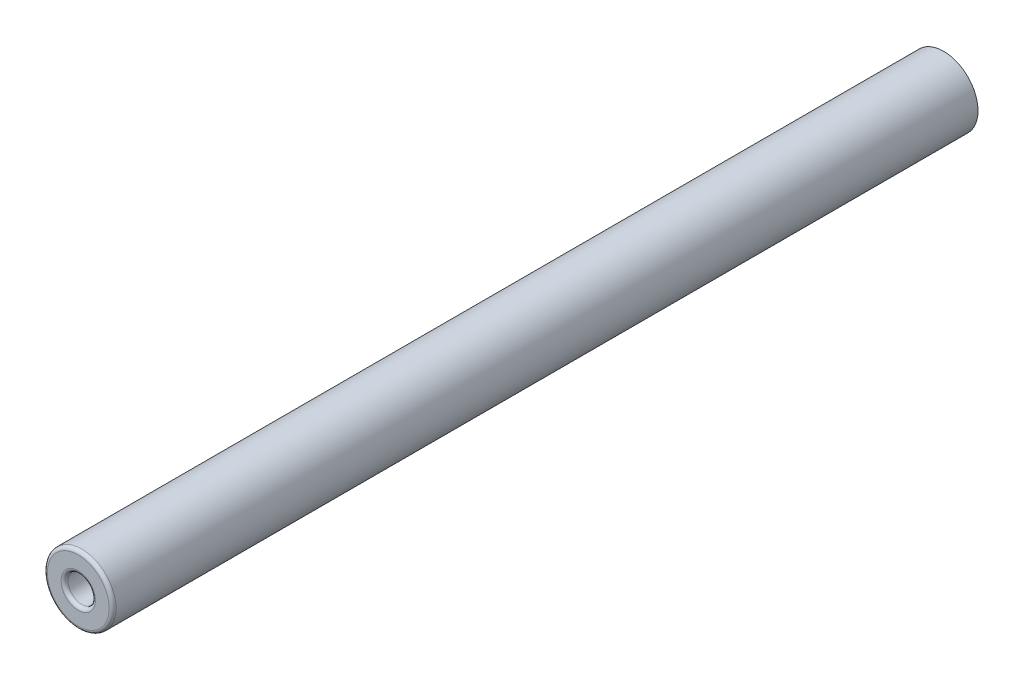
from build123d import *

# Parameters (mm, degrees)
SKETCH1_R           = 2.5
BOSS_EXTRUDE1_DEPTH = 63
SKETCH2_R           = 1
CUT_EXTRUDE1_DEPTH  = 10
FILLET1_R           = 0.25


with BuildPart() as part:
    # Sketch1 → Boss-Extrude1 (new body)
    with BuildSketch(Plane.XY):
        Circle(SKETCH1_R)
    extrude(amount=BOSS_EXTRUDE1_DEPTH)

    # Sketch2 → Cut-Extrude1 (cut)
    with BuildSketch(Plane.XY.offset(63)):
        Circle(SKETCH2_R)
    extrude(amount=-CUT_EXTRUDE1_DEPTH, mode=Mode.SUBTRACT)

    # Fillet1
    fillet1_edges = [part.edges().sort_by_distance(p)[0] for p in [
        (-2.5, 0, 63),
        (-1, 0, 63),
    ]]
    fillet(fillet1_edges, radius=FILLET1_R)


solid = part.part
